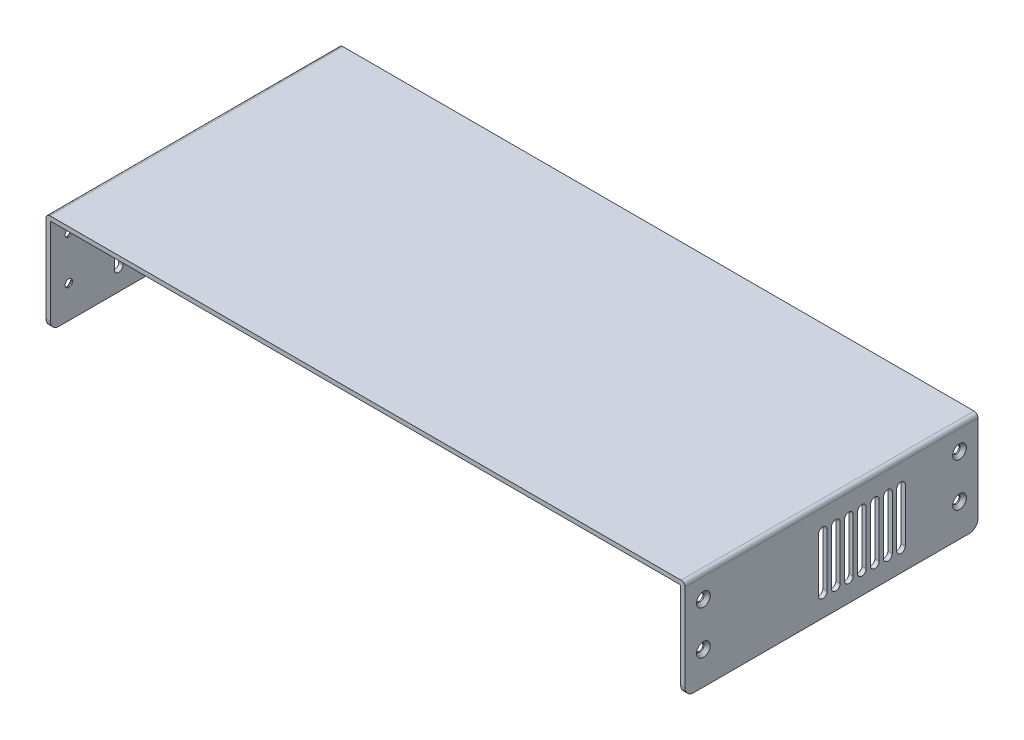
from build123d import *

# Parameters (mm, degrees)
BOSS_EXTRUDE1_DEPTH                             = 135
CSK_FOR_M3_FLAT_HEAD_MACHINE_SCREW1_D           = 3.4
CSK_FOR_M3_FLAT_HEAD_MACHINE_SCREW1_DEPTH       = 5
CSK_FOR_M3_FLAT_HEAD_MACHINE_SCREW1_CSINK_D     = 6.3
CSK_FOR_M3_FLAT_HEAD_MACHINE_SCREW1_CSINK_ANGLE = 90
CSK_FOR_M3_FLAT_HEAD_MACHINE_SCREW1_TIP         = 1.021463052
CSK_FOR_M3_FLAT_HEAD_MACHINE_SCREW2_D           = 3.4
CSK_FOR_M3_FLAT_HEAD_MACHINE_SCREW2_DEPTH       = 5
CSK_FOR_M3_FLAT_HEAD_MACHINE_SCREW2_CSINK_D     = 6.3
CSK_FOR_M3_FLAT_HEAD_MACHINE_SCREW2_CSINK_ANGLE = 90
CSK_FOR_M3_FLAT_HEAD_MACHINE_SCREW2_TIP         = 1.021463052
FILLET1_R                                       = 4
CUT_EXTRUDE1_DEPTH                              = 10
LPATTERN1_COUNT                                 = 13
LPATTERN1_PITCH                                 = 6
CUT_EXTRUDE2_DEPTH                              = 10
LPATTERN2_COUNT                                 = 7
LPATTERN2_PITCH                                 = 6


with BuildPart() as part:
    # Sketch1 → Boss-Extrude1 (new body)
    with BuildSketch(Plane.XY):
        with BuildLine():
            Line((0, 0), (-2, 0))
            Line((-2, 0), (-2, 44.2))
            ThreePointArc((-2, 44.2), (-1.472792206, 45.472792206), (-0.2, 46))
            Line((-0.2, 46), (290.6, 46))
            ThreePointArc((290.6, 46), (291.872792206, 45.472792206), (292.4, 44.2))
            Line((292.4, 44.2), (292.4, 0))
            Line((292.4, 0), (290.4, 0))
            Line((290.4, 0), (290.4, 43.5))
            ThreePointArc((290.4, 43.5), (290.253553391, 43.853553391), (289.9, 44))
            Line((289.9, 44), (0.5, 44))
            ThreePointArc((0.5, 44), (0.146446609, 43.853553391), (0, 43.5))
            Line((0, 43.5), (0, 0))
        make_face()
    extrude(amount=BOSS_EXTRUDE1_DEPTH)

    # CSK for M3 Flat Head Machine Screw1
    with Locations(Plane.ZY.offset(2)):
        with Locations((8.5, 35), (8.5, 15), (126.5, 35), (126.5, 15)):
            CounterSinkHole(CSK_FOR_M3_FLAT_HEAD_MACHINE_SCREW1_D / 2, CSK_FOR_M3_FLAT_HEAD_MACHINE_SCREW1_CSINK_D / 2, depth=CSK_FOR_M3_FLAT_HEAD_MACHINE_SCREW1_DEPTH, counter_sink_angle=CSK_FOR_M3_FLAT_HEAD_MACHINE_SCREW1_CSINK_ANGLE)
            with Locations((0, 0, -(CSK_FOR_M3_FLAT_HEAD_MACHINE_SCREW1_DEPTH + CSK_FOR_M3_FLAT_HEAD_MACHINE_SCREW1_TIP / 2))):  # 118° drill point
                Cone(0, CSK_FOR_M3_FLAT_HEAD_MACHINE_SCREW1_D / 2, CSK_FOR_M3_FLAT_HEAD_MACHINE_SCREW1_TIP, mode=Mode.SUBTRACT)

    # CSK for M3 Flat Head Machine Screw2
    with Locations(Plane(origin=(292.4, 0, 0), x_dir=(0, 0, -1), z_dir=(1, 0, 0))):
        with Locations((-126.5, 35), (-126.5, 15), (-8.5, 35), (-8.5, 15)):
            CounterSinkHole(CSK_FOR_M3_FLAT_HEAD_MACHINE_SCREW2_D / 2, CSK_FOR_M3_FLAT_HEAD_MACHINE_SCREW2_CSINK_D / 2, depth=CSK_FOR_M3_FLAT_HEAD_MACHINE_SCREW2_DEPTH, counter_sink_angle=CSK_FOR_M3_FLAT_HEAD_MACHINE_SCREW2_CSINK_ANGLE)
            with Locations((0, 0, -(CSK_FOR_M3_FLAT_HEAD_MACHINE_SCREW2_DEPTH + CSK_FOR_M3_FLAT_HEAD_MACHINE_SCREW2_TIP / 2))):  # 118° drill point
                Cone(0, CSK_FOR_M3_FLAT_HEAD_MACHINE_SCREW2_D / 2, CSK_FOR_M3_FLAT_HEAD_MACHINE_SCREW2_TIP, mode=Mode.SUBTRACT)

    # Fillet1
    fillet1_edges = [part.edges().sort_by_distance(p)[0] for p in [
        (-1, 0, 0),
        (291.4, 0, 0),
        (291.4, 0, 135),
        (-1, 0, 135),
    ]]
    fillet(fillet1_edges, radius=FILLET1_R)

    # Sketch6 → Cut-Extrude1 (cut)
    with BuildSketch(Plane(origin=(-2, 0, 0), x_dir=(0, 0, -1), z_dir=(1, 0, 0))):
        with BuildLine():
            Line((-101.5, 34.375), (-101.5, 9.8))
            ThreePointArc((-101.5, 9.8), (-103.5, 7.8), (-105.5, 9.8))
            Line((-105.5, 9.8), (-105.5, 34.375))
            ThreePointArc((-105.5, 34.375), (-103.5, 36.375), (-101.5, 34.375))
        make_face()
    cut_extrude1 = extrude(amount=CUT_EXTRUDE1_DEPTH, mode=Mode.SUBTRACT)

    # LPattern1: Cut-Extrude1 ×13
    with Locations(*[(0, 0, -i * LPATTERN1_PITCH) for i in range(1, LPATTERN1_COUNT)]):
        add(cut_extrude1, mode=Mode.SUBTRACT)

    # Sketch7 → Cut-Extrude2 (cut)
    with BuildSketch(Plane(origin=(292.4, 0, 0), x_dir=(0, 0, -1), z_dir=(1, 0, 0))):
        with BuildLine():
            Line((-33.5, 34.375), (-33.5, 9.8))
            ThreePointArc((-33.5, 9.8), (-35.5, 7.8), (-37.5, 9.8))
            Line((-37.5, 9.8), (-37.5, 34.375))
            ThreePointArc((-37.5, 34.375), (-35.5, 36.375), (-33.5, 34.375))
        make_face()
    cut_extrude2 = extrude(amount=-CUT_EXTRUDE2_DEPTH, mode=Mode.SUBTRACT)

    # LPattern2: Cut-Extrude2 ×7
    with Locations(*[(0, 0, i * LPATTERN2_PITCH) for i in range(1, LPATTERN2_COUNT)]):
        add(cut_extrude2, mode=Mode.SUBTRACT)


solid = part.part
